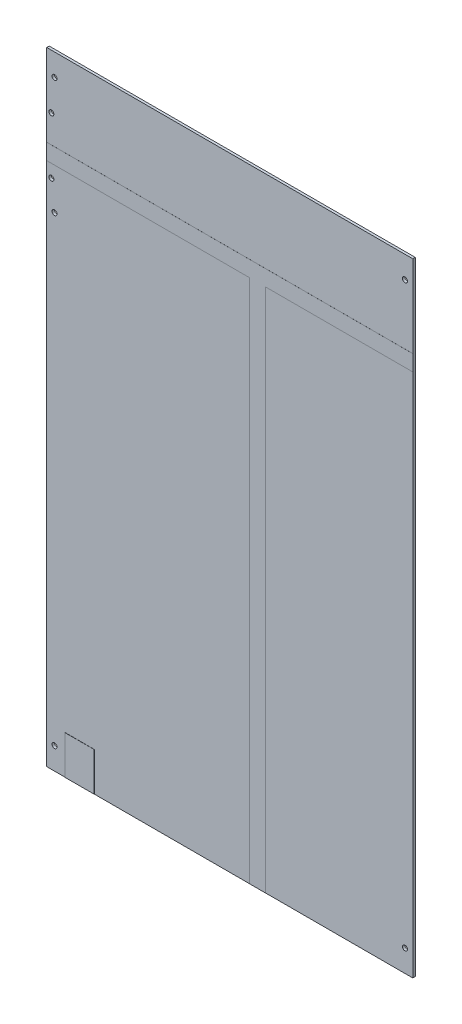
from build123d import *

# Parameters (mm, degrees)
SKETCH1_W                = 234.4674
SKETCH1_H                = 398.9197
BOSS_EXTRUDE1_DEPTH      = 1.5875
BOSS_EXTRUDE2_DEPTH      = 0.0254
BOSS_EXTRUDE2_DEPTH_BACK = 1.6254
SKETCH5_R                = 1.6
CUT_EXTRUDE1_DEPTH       = 2.6254
SKETCH6_W                = 18.565945636
SKETCH6_H                = 24.802104659
BOSS_EXTRUDE3_DEPTH      = 0.1
SKETCH8_R                = 1.6
CUT_EXTRUDE2_DEPTH       = 2.6254
SKETCH7_R                = 1.6
CUT_EXTRUDE3_DEPTH       = 10


with BuildPart() as part:
    # Sketch1 → Boss-Extrude1 (new body)
    with BuildSketch(Plane.XY):
        with Locations((0, -141.80185)):
            Rectangle(SKETCH1_W, SKETCH1_H)
    extrude(amount=BOSS_EXTRUDE1_DEPTH)

    # Sketch4 → Boss-Extrude2 (add, two sides)
    with BuildSketch(Plane.XY.offset(1.5875)) as boss_extrude2_sk:
        Polygon((-117.2337, 5.08), (117.2337, 5.08), (117.2337, -5.08), (22.987, -5.08), (22.987, -341.2617), (12.827, -341.2617), (12.827, -5.08), (-117.2337, -5.08), align=None)
    extrude(amount=BOSS_EXTRUDE2_DEPTH)
    extrude(boss_extrude2_sk.sketch, amount=-BOSS_EXTRUDE2_DEPTH_BACK)

    # Sketch5 → Cut-Extrude1 (cut, through all)
    with BuildSketch(Plane.XY.offset(1.5875)):
        with Locations((112.2337, 43.514)):
            Circle(SKETCH5_R)
        with Locations((112.2337, -327.1177)):
            Circle(SKETCH5_R)
    cut_extrude1 = extrude(amount=-CUT_EXTRUDE1_DEPTH, mode=Mode.SUBTRACT)

    # Mirror3: Cut-Extrude1 across plane
    add(cut_extrude1.mirror(Plane(origin=(0, 0, 0), x_dir=(0, 0, 1), z_dir=(1, 0, 0))), mode=Mode.SUBTRACT)

    # Sketch6 → Boss-Extrude3 (add)
    with BuildSketch(Plane.XY.offset(1.5875)):
        with Locations((-96.012, -328.860647671)):
            Rectangle(SKETCH6_W, SKETCH6_H)
    extrude(amount=BOSS_EXTRUDE3_DEPTH)

    # Sketch8 → Cut-Extrude2 (cut, through all)
    with BuildSketch(Plane.XY.offset(1.5875)):
        with Locations((-114.2337, 22.85873)):
            Circle(SKETCH8_R)
        with Locations((-114.2337, -13.33627)):
            Circle(SKETCH8_R)
    extrude(amount=-CUT_EXTRUDE2_DEPTH, mode=Mode.SUBTRACT)

    # Sketch7 → Cut-Extrude3 (cut)
    with BuildSketch(Plane.XY.offset(1.5875)):
        with Locations((-112.2337, -31.486)):
            Circle(SKETCH7_R)
    extrude(amount=-CUT_EXTRUDE3_DEPTH, mode=Mode.SUBTRACT)


solid = part.part
